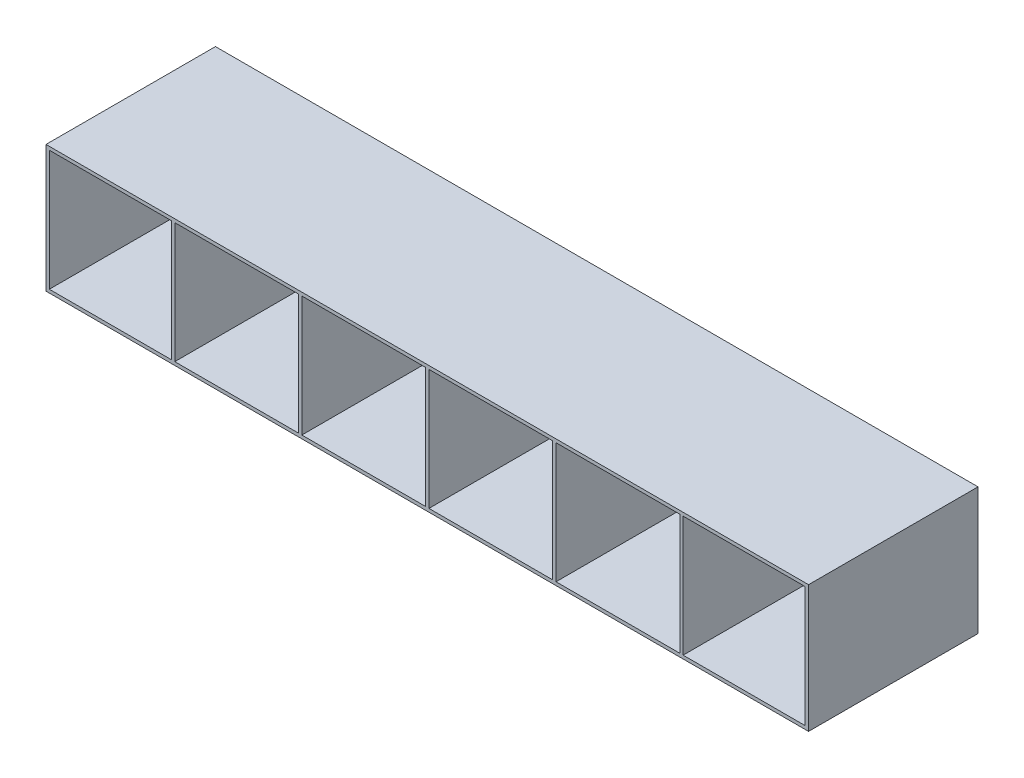
from build123d import *

# Parameters (mm, degrees)
SKETCH_1_W          = 457.2
SKETCH_1_H          = 76.2
EXTRUDE_1_DEPTH     = 101.6
SKETCH_1_3_W        = 73.2
SKETCH_1_3_H        = 72.2
SKETCH_1_3_W_2      = 74.2
CUT_EXTRUDE_1_DEPTH = 254.045707334


with BuildPart() as part:
    # Эскиз1 → Бобышка-Вытянуть1 (new body)
    with BuildSketch(Plane.XY):
        Rectangle(SKETCH_1_W, SKETCH_1_H)
    extrude(amount=EXTRUDE_1_DEPTH)

    # Эскиз1<3> → Вырез-Вытянуть1 (cut, through all)
    with BuildSketch(Plane.XY):
        with Locations((-190, 0)):
            Rectangle(SKETCH_1_3_W, SKETCH_1_3_H)
        with Locations((-114.3, 0)):
            Rectangle(SKETCH_1_3_W_2, SKETCH_1_3_H)
        with Locations((-38.1, 0)):
            Rectangle(SKETCH_1_3_W_2, SKETCH_1_3_H)
        with Locations((38.1, 0)):
            Rectangle(SKETCH_1_3_W_2, SKETCH_1_3_H)
        with Locations((114.3, 0)):
            Rectangle(SKETCH_1_3_W_2, SKETCH_1_3_H)
        with Locations((190, 0)):
            Rectangle(SKETCH_1_3_W, SKETCH_1_3_H)
    extrude(amount=CUT_EXTRUDE_1_DEPTH, mode=Mode.SUBTRACT)


solid = part.part
